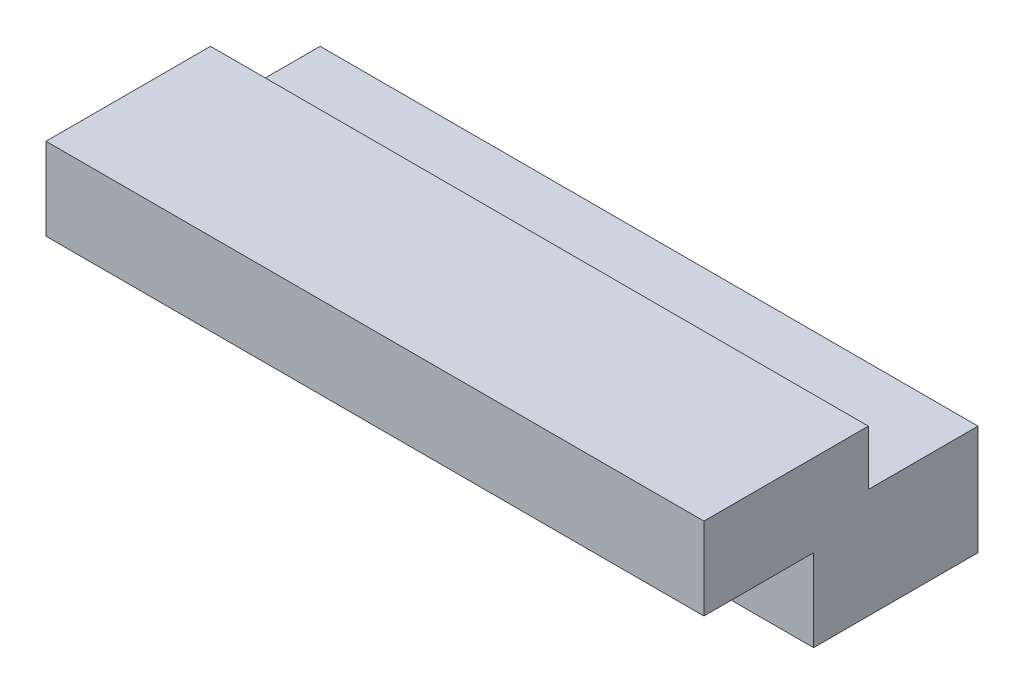
from build123d import *

# Parameters (mm, degrees)
SKETCH_3_W      = 60
SKETCH_3_H      = 10
EXTRUDE_1_DEPTH = 10
SKETCH_4_W      = 60
SKETCH_4_H      = 10
EXTRUDE_2_DEPTH = 5
SKETCH_5_W      = 60
SKETCH_5_H      = 5
EXTRUDE_3_DEPTH = 5
SKETCH_6_W      = 60
SKETCH_6_H      = 7.5
EXTRUDE_4_DEPTH = 10


with BuildPart() as part:
    # 草图3 → 凸台-拉伸1 (new body)
    with BuildSketch(Plane.XZ.offset(-0.087836635)):
        with Locations((26.631510997, 9.323973154)):
            Rectangle(SKETCH_3_W, SKETCH_3_H)
    extrude(amount=EXTRUDE_1_DEPTH)

    # 草图4 → 凸台-拉伸2 (add)
    with BuildSketch(Plane.XY.offset(14.323973154)):
        with Locations((26.631510997, -4.912163365)):
            Rectangle(SKETCH_4_W, SKETCH_4_H)
    extrude(amount=EXTRUDE_2_DEPTH)

    # 草图5 → 凸台-拉伸3 (add)
    with BuildSketch(Plane(origin=(0, 0.087836635, 0), x_dir=(1, 0, 0), z_dir=(0, 1, 0))):
        with Locations((26.631510997, -16.823973154)):
            Rectangle(SKETCH_5_W, SKETCH_5_H)
    extrude(amount=EXTRUDE_3_DEPTH)

    # 草图6 → 凸台-拉伸4 (add)
    with BuildSketch(Plane.XY.offset(19.323973154)):
        with Locations((26.631510997, 1.337836635)):
            Rectangle(SKETCH_6_W, SKETCH_6_H)
    extrude(amount=EXTRUDE_4_DEPTH)


solid = part.part
